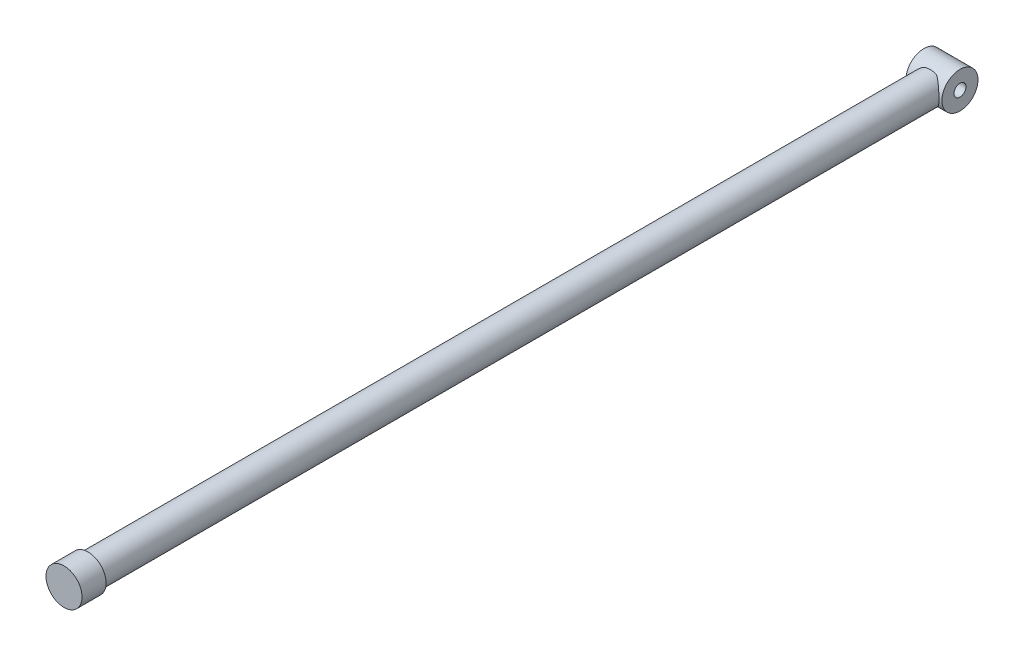
from build123d import *

# Parameters (mm, degrees)
IZIM1_R                     = 1.5
Y_KSEKLIK_EKSTR_ZYON1_DEPTH = 1
IZIM2_R                     = 1.25
Y_KSEKLIK_EKSTR_ZYON2_DEPTH = 70
IZIM5_R                     = 1.5
IZIM5_R_2                   = 0.5
Y_KSEKLIK_EKSTR_ZYON5_DEPTH = 1.5


with BuildPart() as part:
    # Çizim1 → Yükseklik-Ekstrüzyon1 (new body, symmetric)
    with BuildSketch(Plane.XY):
        Circle(IZIM1_R)
    extrude(amount=Y_KSEKLIK_EKSTR_ZYON1_DEPTH, both=True)

    # Çizim2 → Yükseklik-Ekstrüzyon2 (add)
    with BuildSketch(Plane(origin=(0, 0, -1), x_dir=(-1, 0, 0), z_dir=(0, 0, -1))):
        Circle(IZIM2_R)
    extrude(amount=Y_KSEKLIK_EKSTR_ZYON2_DEPTH)

    # Çizim5 → Yükseklik-Ekstrüzyon5 (add, symmetric)
    with BuildSketch(Plane(origin=(0, 0, 0), x_dir=(0, 0, -1), z_dir=(1, 0, 0))):
        with Locations((72, 0)):
            Circle(IZIM5_R)
        with Locations((72, 0)):
            Circle(IZIM5_R_2, mode=Mode.SUBTRACT)
    extrude(amount=Y_KSEKLIK_EKSTR_ZYON5_DEPTH, both=True)


solid = part.part
